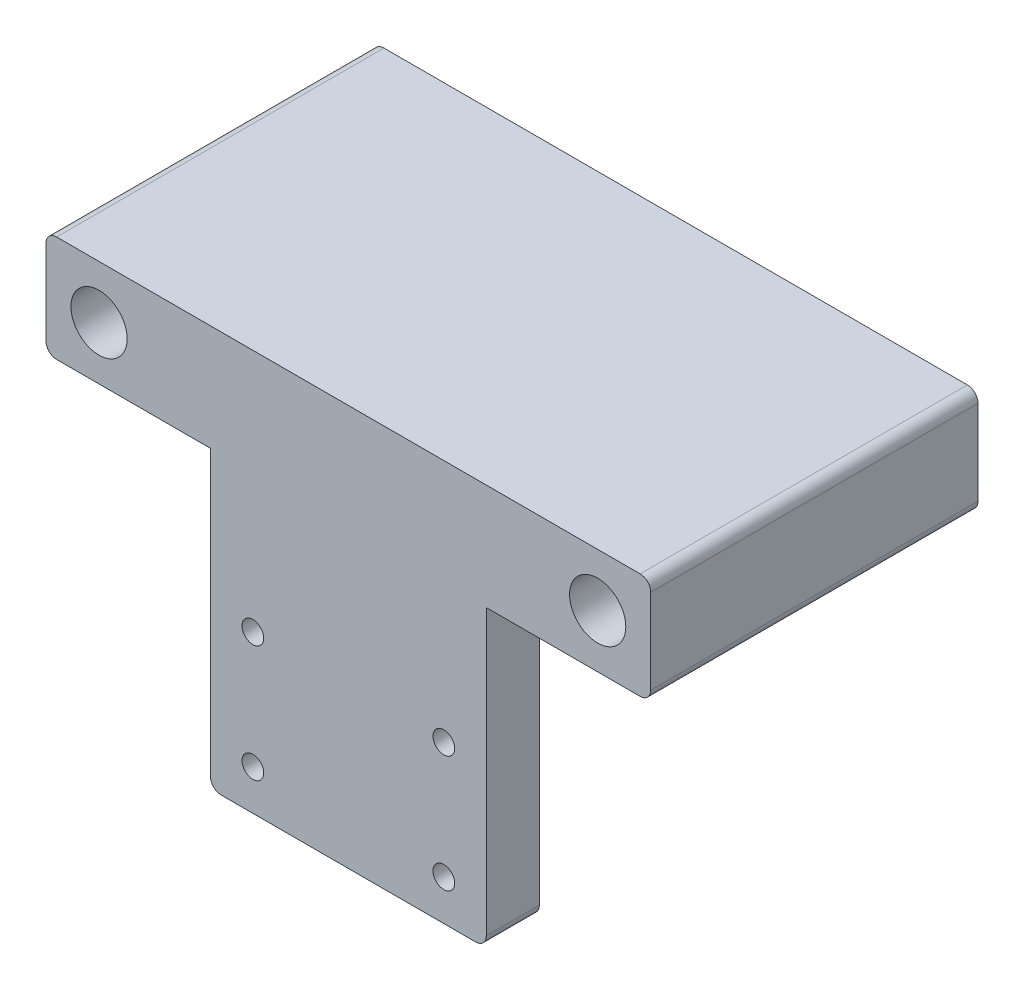
from build123d import *

# Parameters (mm, degrees)
PCB_MOUNT_DEPTH                = 5
STEPPER_OFFSET_MOUNT_DEPTH     = 25.85
M5_CLEARANCE_HOLE1_D           = 5.3
TAP_DRILL_FOR_M2_5X0_45_TAP1_D = 2.05
FILLET1_R                      = 1
FILLET2_R                      = 1


with BuildPart() as part:
    # Body Sketch → PCB Mount (new body)
    with BuildSketch(Plane.XY):
        Polygon((-28.5, 28.5), (-28.5, 18.5), (-13, 18.5), (-13, -9.3), (13, -9.3), (13, 18.5), (28.5, 18.5), (28.5, 28.5), align=None)
    extrude(amount=PCB_MOUNT_DEPTH)

    # Body Sketch_6 → Stepper Offset Mount (add)
    with BuildSketch(Plane.XY):
        Polygon((-28.5, 28.5), (-28.5, 18.5), (-13, 18.5), (13, 18.5), (28.5, 18.5), (28.5, 28.5), align=None)
    extrude(amount=-STEPPER_OFFSET_MOUNT_DEPTH)

    # M5 Clearance Hole1 (through all)
    with Locations(Plane.XY.offset(5)):
        with Locations((-23.5, 23.5), (23.5, 23.5)):
            Hole(M5_CLEARANCE_HOLE1_D / 2)

    # Tap Drill for M2.5x0.45 Tap1 (through all)
    with Locations(Plane.XY.offset(5)):
        with Locations((-9, 5.5), (-9, -5.5), (9, -5.5), (9, 5.5)):
            Hole(TAP_DRILL_FOR_M2_5X0_45_TAP1_D / 2)

    # Fillet1
    fillet1_edges = [part.edges().sort_by_distance(p)[0] for p in [
        (-28.5, 18.5, -10.425),
        (-28.5, 28.5, -10.425),
        (28.5, 28.5, -10.425),
        (28.5, 18.5, -10.425),
    ]]
    fillet(fillet1_edges, radius=FILLET1_R)

    # Fillet2
    fillet2_edges = [part.edges().sort_by_distance(p)[0] for p in [
        (13, -9.3, 2.5),
        (-13, -9.3, 2.5),
    ]]
    fillet(fillet2_edges, radius=FILLET2_R)


solid = part.part
